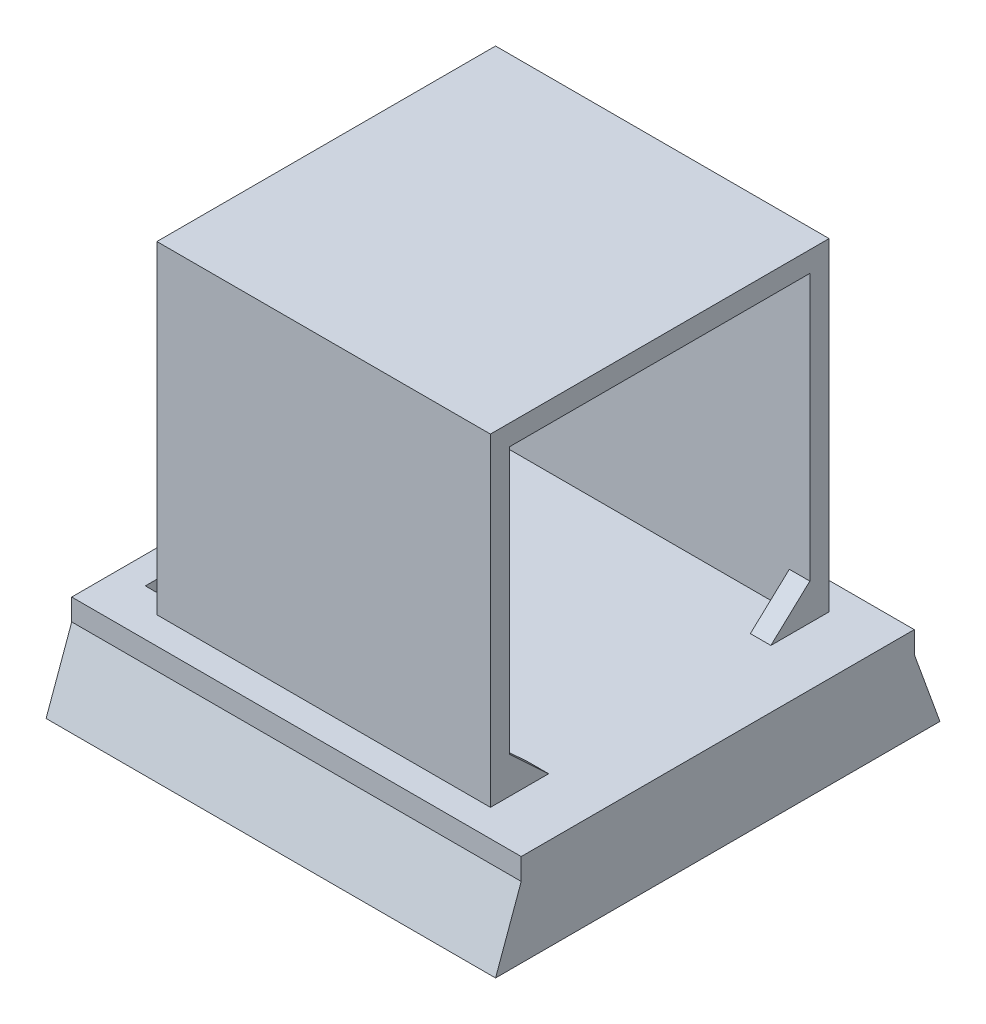
from build123d import *

# Parameters (mm, degrees)
SKETCH1_W                = 30
SKETCH1_H                = 29
SKETCH1_R                = 1.75
BOSS_EXTRUDE1_DEPTH      = 2
SKETCH2_W                = 43.8
SKETCH2_H                = 38.3
BOSS_EXTRUDE3_DEPTH      = 9
BOSS_EXTRUDE4_DEPTH      = 43.8
SKETCH16_W               = 2
SKETCH16_H               = 29
CUT_EXTRUDE1_DEPTH       = 26.5
SKETCH15_W               = 32.5
SKETCH15_H               = 31.5
BOSS_EXTRUDE5_DEPTH      = 2
BOSS_EXTRUDE5_DEPTH_BACK = 31
SKETCH20_W               = 29.25
SKETCH20_H               = 29.5
CUT_EXTRUDE2_DEPTH       = 22.9
CUT_EXTRUDE2_DEPTH_BACK  = 22.9
BOSS_EXTRUDE6_DEPTH      = 2
SKETCH22_W               = 3
SKETCH22_H               = 29.25
CUT_EXTRUDE3_DEPTH       = 2


with BuildPart() as part:
    # Sketch1 → Boss-Extrude1 (new body)
    with BuildSketch(Plane.XY):
        Rectangle(SKETCH1_W, SKETCH1_H)
        with Locations((-8.45, 8.168333333)):
            Circle(SKETCH1_R, mode=Mode.SUBTRACT)
        with Locations((8.168333333, 8.45)):
            Circle(SKETCH1_R, mode=Mode.SUBTRACT)
        with Locations((8.45, -8.168333333)):
            Circle(SKETCH1_R, mode=Mode.SUBTRACT)
        with Locations((-8.168333333, -8.45)):
            Circle(SKETCH1_R, mode=Mode.SUBTRACT)
    extrude(amount=BOSS_EXTRUDE1_DEPTH)

    # Sketch2 → Boss-Extrude3 (add)
    with BuildSketch(Plane.XZ.offset(14.5)):
        with Locations((0, 19.15)):
            Rectangle(SKETCH2_W, SKETCH2_H)
    extrude(amount=BOSS_EXTRUDE3_DEPTH)

    # Sketch3 → Boss-Extrude4 (add)
    with BuildSketch(Plane.ZY.offset(21.9)):
        Polygon((0, -23.5), (-2.5, -23.5), (0, -16.6), align=None)
        Polygon((38.3, -23.5), (40.8, -23.5), (38.3, -16.6), align=None)
    extrude(amount=-BOSS_EXTRUDE4_DEPTH)

    # Sketch16 → Cut-Extrude1 (cut, symmetric)
    with BuildSketch(Plane(origin=(0, 0, 0), x_dir=(0, 0, -1), z_dir=(1, 0, 0))):
        with Locations((-1, 0)):
            Rectangle(SKETCH16_W, SKETCH16_H)
    extrude(amount=CUT_EXTRUDE1_DEPTH, both=True, mode=Mode.SUBTRACT)

    # Sketch15 → Boss-Extrude5 (add, two sides)
    with BuildSketch(Plane(origin=(0, 0, 4.65), x_dir=(-1, 0, 0), z_dir=(0, 0, -1))) as boss_extrude5_sk:
        with Locations((0, 1.25)):
            Rectangle(SKETCH15_W, SKETCH15_H)
    extrude(amount=BOSS_EXTRUDE5_DEPTH)
    extrude(boss_extrude5_sk.sketch, amount=-BOSS_EXTRUDE5_DEPTH_BACK)

    # Sketch20 → Cut-Extrude2 (cut, two sides)
    with BuildSketch(Plane(origin=(0, 0, 0), x_dir=(0, 0, -1), z_dir=(1, 0, 0))) as cut_extrude2_sk:
        with Locations((-19.15, 0.25)):
            Rectangle(SKETCH20_W, SKETCH20_H)
    extrude(amount=CUT_EXTRUDE2_DEPTH, mode=Mode.SUBTRACT)
    extrude(cut_extrude2_sk.sketch, amount=-CUT_EXTRUDE2_DEPTH_BACK, mode=Mode.SUBTRACT)

    # Sketch21 → Boss-Extrude6 (add)
    with BuildSketch(Plane(origin=(16.25, 0, 0), x_dir=(0, 0, -1), z_dir=(1, 0, 0))):
        Polygon((-35.65, -10.971015683), (-33.775, -10.971015683), (-29.976700434, -14.5), (-35.65, -14.5), align=None)
        Polygon((-4.525, -10.971015683), (-8.323299566, -14.5), (-2.65, -14.5), (-2.65, -10.971015683), align=None)
    extrude(amount=-BOSS_EXTRUDE6_DEPTH)

    # Sketch22 → Cut-Extrude3 (cut)
    with BuildSketch(Plane(origin=(0, -14.5, 0), x_dir=(1, 0, 0), z_dir=(0, 1, 0))):
        with Locations((-17.75, -19.15)):
            Rectangle(SKETCH22_W, SKETCH22_H)
    extrude(amount=-CUT_EXTRUDE3_DEPTH, mode=Mode.SUBTRACT)


solid = part.part
